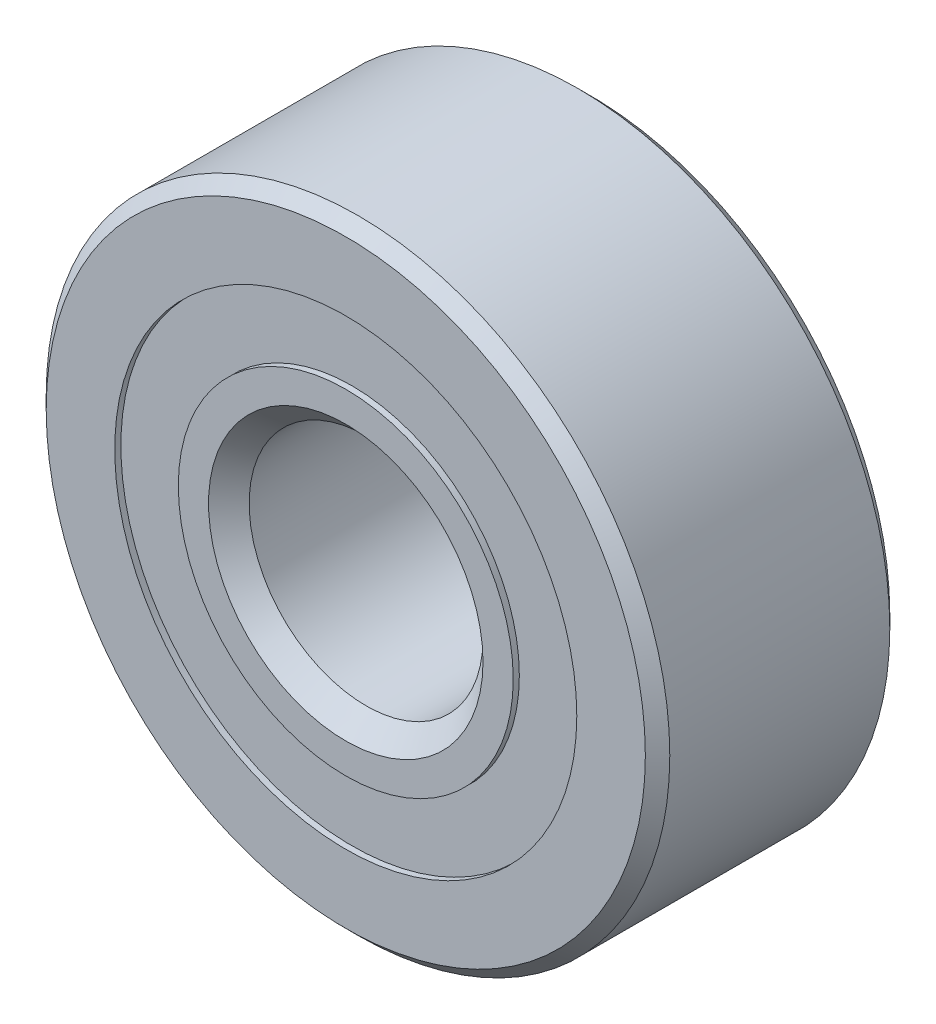
from build123d import *

# Parameters (mm, degrees)
CIRPATTERN1_COUNT = 8
SKETCH5_W         = 1.207534705
SKETCH5_H         = 1.294511557


with BuildPart() as part:
    # Sketch1 → Revolve1 (revolve)
    with BuildSketch(Plane(origin=(0, 0, 0), x_dir=(0, 0, -1), z_dir=(1, 0, 0))):
        with BuildLine():
            Line((2.24028, 6.35), (-2.24028, 6.35))
            Line((-2.24028, 6.35), (-2.4892, 6.10108))
            Line((-2.4892, 6.10108), (-2.4892, 4.705035989))
            Line((-2.4892, 4.705035989), (-1.106311111, 4.705035989))
            ThreePointArc((-1.106311111, 4.705035989), (0, 5.522830295), (1.106311111, 4.705035989))
            Line((1.106311111, 4.705035989), (2.4892, 4.705035989))
            Line((2.4892, 4.705035989), (2.4892, 6.10108))
            Line((2.4892, 6.10108), (2.24028, 6.35))
        make_face()
    revolve(axis=Axis((0, 0, 2.4892), (0, 0, -1)))


with BuildPart() as body_2:
    # Sketch3 → Revolve3 (revolve)
    with BuildSketch(Plane(origin=(0, 0, 0), x_dir=(0, 0, -1), z_dir=(1, 0, 0))):
        with BuildLine():
            Line((-2.36474, 3.286064432), (-1.873510421, 2.794834853))
            Line((-1.873510421, 2.794834853), (0, 2.794834853))
            Line((0, 2.794834853), (0, 3.208419705))
            ThreePointArc((0, 3.208419705), (0.687879314, 3.435062727), (1.106311111, 4.026214011))
            Line((1.106311111, 4.026214011), (2.4892, 4.026214011))
            Line((2.4892, 4.026214011), (2.4892, 2.63017))
            Line((2.4892, 2.63017), (2.24028, 2.38125))
            Line((2.24028, 2.38125), (-2.075615147, 2.38125))
            Line((-2.075615147, 2.38125), (-2.4892, 2.794834853))
            Line((-2.4892, 2.794834853), (-2.4892, 3.410524432))
            Line((-2.4892, 3.410524432), (-2.36474, 3.410524432))
            Line((-2.36474, 3.410524432), (-2.36474, 3.286064432))
        make_face()
    revolve(axis=Axis((0, 0, 2.4892), (0, 0, -1)))


with BuildPart() as body_3:
    # Sketch4 → Revolve4 (revolve)
    with BuildSketch(Plane(origin=(0, 0, 0), x_dir=(0, 0, -1), z_dir=(1, 0, 0))):
        with BuildLine():
            Line((-1.157205295, 4.365625), (1.157205295, 4.365625))
            ThreePointArc((1.157205295, 4.365625), (0, 5.522830295), (-1.157205295, 4.365625))
        make_face()
    revolve(axis=Axis((0, 4.365625, 1.157205295), (0, 0, -1)))


with BuildPart() as cirpattern1_1:
    # CirPattern1: pattern copy
    add(body_3.part.rotate(Axis((0, 0, -2.4892), (0, 0, 1)), 1 * 360 / CIRPATTERN1_COUNT))


with BuildPart() as cirpattern1_2:
    # CirPattern1: pattern copy
    add(body_3.part.rotate(Axis((0, 0, -2.4892), (0, 0, 1)), 2 * 360 / CIRPATTERN1_COUNT))


with BuildPart() as cirpattern1_3:
    # CirPattern1: pattern copy
    add(body_3.part.rotate(Axis((0, 0, -2.4892), (0, 0, 1)), 3 * 360 / CIRPATTERN1_COUNT))


with BuildPart() as cirpattern1_4:
    # CirPattern1: pattern copy
    add(body_3.part.rotate(Axis((0, 0, -2.4892), (0, 0, 1)), 4 * 360 / CIRPATTERN1_COUNT))


with BuildPart() as cirpattern1_5:
    # CirPattern1: pattern copy
    add(body_3.part.rotate(Axis((0, 0, -2.4892), (0, 0, 1)), 5 * 360 / CIRPATTERN1_COUNT))


with BuildPart() as cirpattern1_6:
    # CirPattern1: pattern copy
    add(body_3.part.rotate(Axis((0, 0, -2.4892), (0, 0, 1)), 6 * 360 / CIRPATTERN1_COUNT))


with BuildPart() as cirpattern1_7:
    # CirPattern1: pattern copy
    add(body_3.part.rotate(Axis((0, 0, -2.4892), (0, 0, 1)), 7 * 360 / CIRPATTERN1_COUNT))


with BuildPart() as body_11:
    # Sketch5 → Revolve5 (revolve)
    with BuildSketch(Plane(origin=(0, 0, 0), x_dir=(0, 0, -1), z_dir=(1, 0, 0))):
        with Locations((-1.760972648, 4.057780211)):
            Rectangle(SKETCH5_W, SKETCH5_H)
        with Locations((1.760972648, 4.057780211)):
            Rectangle(SKETCH5_W, SKETCH5_H)
    revolve(axis=Axis((0, 0, 2.4892), (0, 0, -1)))


solid = Compound([part.part, body_2.part, body_3.part, cirpattern1_1.part, cirpattern1_2.part, cirpattern1_3.part, cirpattern1_4.part, cirpattern1_5.part, cirpattern1_6.part, cirpattern1_7.part, body_11.part])
